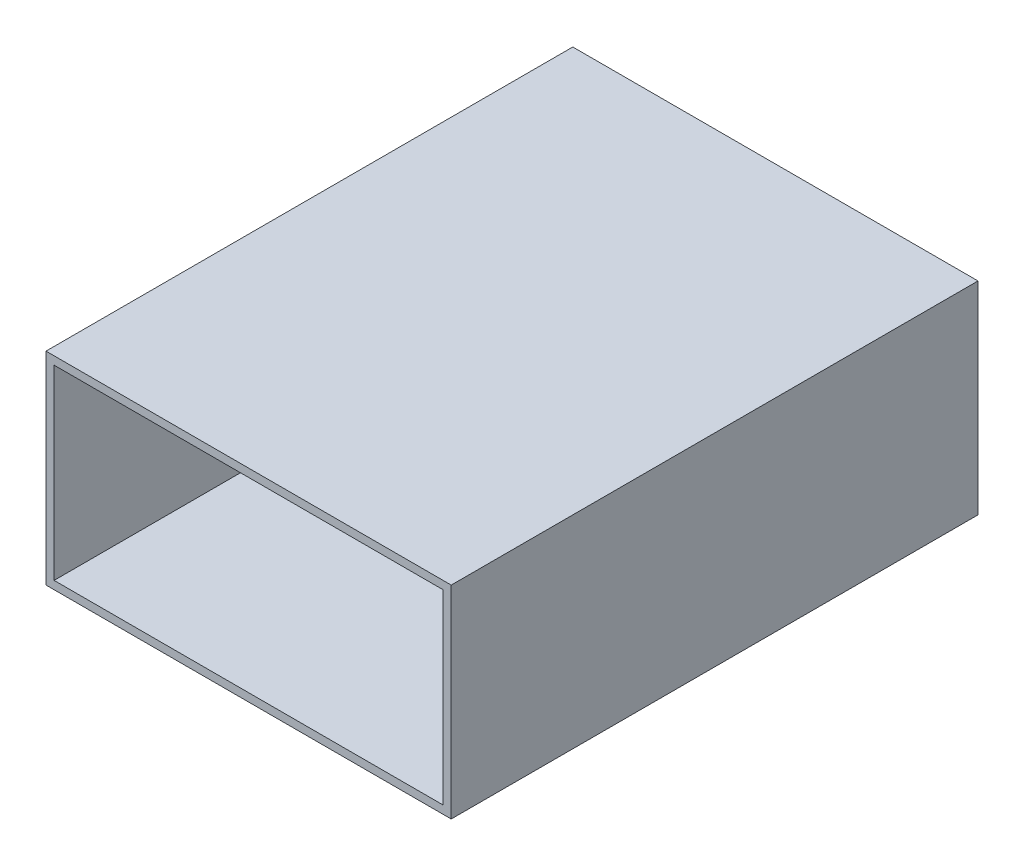
from build123d import *

# Parameters (mm, degrees)
SKETCH1_W           = 50
SKETCH1_H           = 25
SKETCH1_W_2         = 48
SKETCH1_H_2         = 23
BOSS_EXTRUDE1_DEPTH = 65


with BuildPart() as part:
    # Sketch1 → Boss-Extrude1 (new body)
    with BuildSketch(Plane.XY):
        Rectangle(SKETCH1_W, SKETCH1_H)
        Rectangle(SKETCH1_W_2, SKETCH1_H_2, mode=Mode.SUBTRACT)
    extrude(amount=BOSS_EXTRUDE1_DEPTH)


solid = part.part
